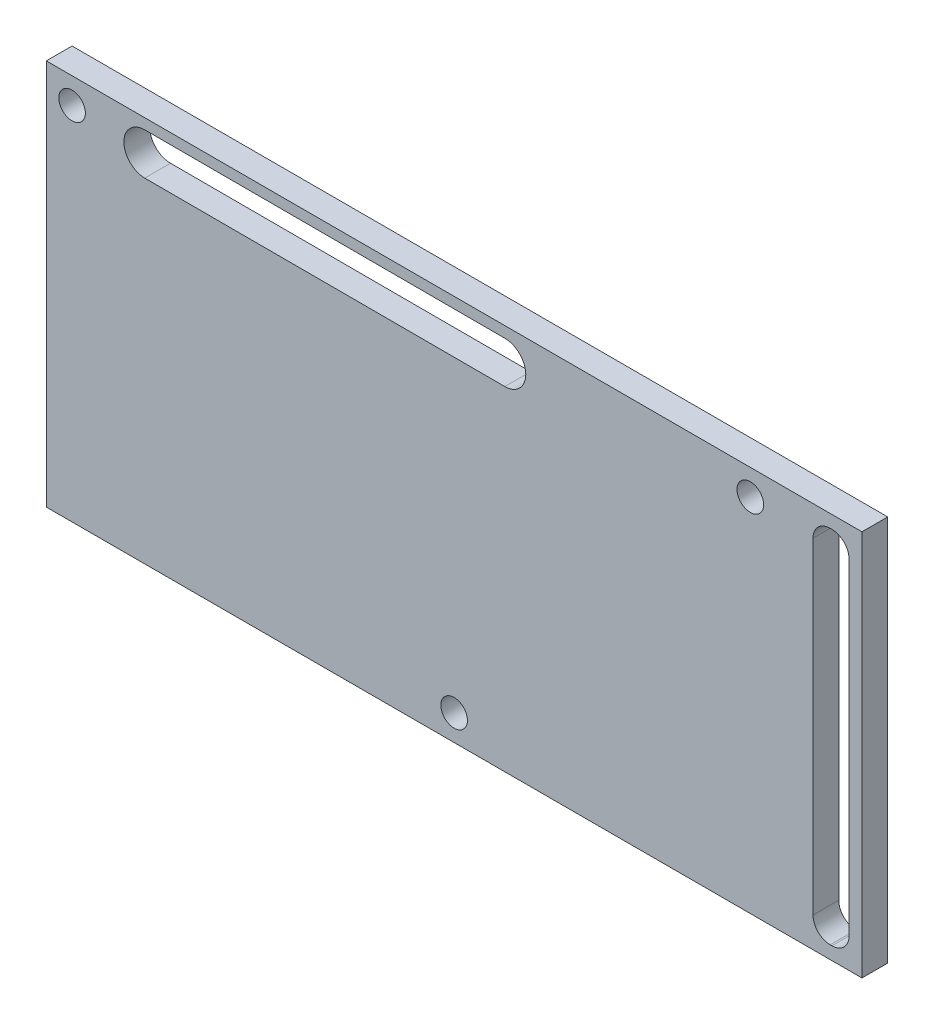
from build123d import *

# Parameters (mm, degrees)
SKETCH4_W           = 95
SKETCH4_H           = 45.00899887
SKETCH4_R           = 1.54999944
BOSS_EXTRUDE6_DEPTH = 3


with BuildPart() as part:
    # Sketch4 → Boss-Extrude6 (new body)
    with BuildSketch(Plane.XY):
        with Locations((8.24074008, 34.620274583)):
            Rectangle(SKETCH4_W, SKETCH4_H)
        with Locations((42.74074118, 54.124774018)):
            Circle(SKETCH4_R, mode=Mode.SUBTRACT)
        with Locations((8.24073906, 15.115774228)):
            Circle(SKETCH4_R, mode=Mode.SUBTRACT)
        with Locations((-36.25926084, 54.124774018)):
            Circle(SKETCH4_R, mode=Mode.SUBTRACT)
        with BuildLine():
            Line((52.04074008, 55.624774018), (52.24074008, 55.624774018))
            ThreePointArc((52.24074008, 55.624774018), (53.654953642, 55.038987581), (54.24074008, 53.624774018))
            Line((54.24074008, 53.624774018), (54.24074008, 15.615775148))
            ThreePointArc((54.24074008, 15.615775148), (53.654953642, 14.201561585), (52.24074008, 13.615775148))
            Line((52.24074008, 13.615775148), (52.04074008, 13.615775148))
            ThreePointArc((52.04074008, 13.615775148), (50.626526517, 14.201561585), (50.04074008, 15.615775148))
            Line((50.04074008, 15.615775148), (50.04074008, 53.624774018))
            ThreePointArc((50.04074008, 53.624774018), (50.626526517, 55.038987581), (52.04074008, 55.624774018))
        make_face(mode=Mode.SUBTRACT)
        with BuildLine():
            Line((14.14745222, 50.977241122), (-27.788451431, 51.033818491))
            ThreePointArc((-27.788451431, 51.033818491), (-30.220596767, 53.472535297), (-27.781879961, 55.904680633))
            Line((-27.781879961, 55.904680633), (14.15402369, 55.848103264))
            ThreePointArc((14.15402369, 55.848103264), (16.586169026, 53.409386458), (14.14745222, 50.977241122))
        make_face(mode=Mode.SUBTRACT)
    extrude(amount=BOSS_EXTRUDE6_DEPTH)


solid = part.part
